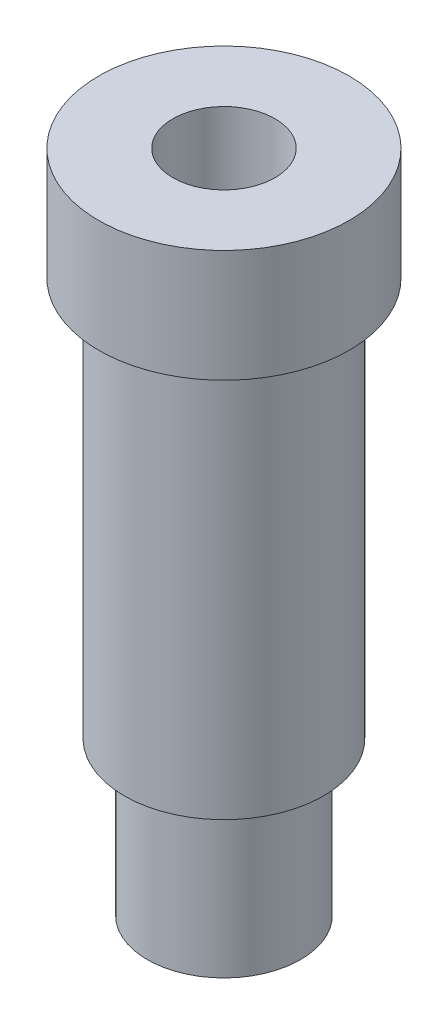
from build123d import *

# Parameters (mm, degrees)
ESQUISSE2_R             = 1
ENL_V_MAT_EXTRU_1_DEPTH = 14


with BuildPart() as part:
    # Esquisse1 → Révolution2 (revolve)
    with BuildSketch(Plane.XY, mode=Mode.PRIVATE) as r_volution2_sk:
        Polygon((0, 13), (2.45, 13), (2.45, 10.8), (1.95, 10.8), (1.95, 3), (1.5, 3), (1.5, 0), (0, 0), align=None)
    revolve(r_volution2_sk.sketch.rotate(Axis((0, -2.821668774, 0), (0, 1, 0)), 90), axis=Axis((0, -2.821668774, 0), (0, 1, 0)))  # turned: the seam where the file's is

    # Esquisse2 → Enlèv. mat.-Extru.1 (cut, through all)
    with BuildSketch(Plane(origin=(0, 13, 0), x_dir=(-1, 0, 0), z_dir=(0, 1, 0))):
        with Locations(Location((0, 0, 0), (0, 0, 90))):  # turned: the seam where the file's is
            Circle(ESQUISSE2_R)
    extrude(amount=-ENL_V_MAT_EXTRU_1_DEPTH, mode=Mode.SUBTRACT)


solid = part.part
